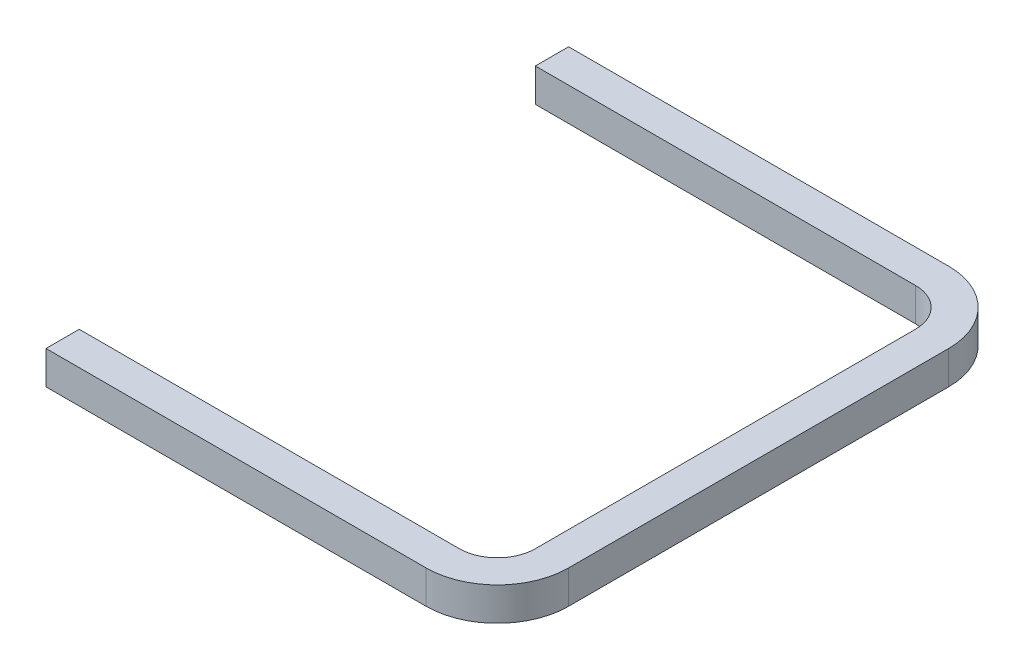
from build123d import *

# Parameters (mm, degrees)
EXTRUDE_THIN1_DEPTH = 22.225


with BuildPart() as part:
    # Sketch2 → Extrude-Thin1 (new body)
    with BuildSketch(Plane(origin=(0, 0, 0), x_dir=(1, 0, 0), z_dir=(0, 1, 0))):
        with BuildLine():
            Line((-127, 152.4), (127, 152.4))
            ThreePointArc((127, 152.4), (144.960512242, 144.960512242), (152.4, 127))
            Line((152.4, 127), (152.4, -127))
            ThreePointArc((152.4, -127), (144.960512242, -144.960512242), (127, -152.4))
            Line((127, -152.4), (-127, -152.4))
            Line((-127, -152.4), (-127, -174.625))
            Line((-127, -174.625), (127, -174.625))
            ThreePointArc((127, -174.625), (160.675960454, -160.675960454), (174.625, -127))
            Line((174.625, -127), (174.625, 127))
            ThreePointArc((174.625, 127), (160.675960454, 160.675960454), (127, 174.625))
            Line((127, 174.625), (-127, 174.625))
            Line((-127, 174.625), (-127, 152.4))
        make_face()
    extrude(amount=EXTRUDE_THIN1_DEPTH)


solid = part.part
